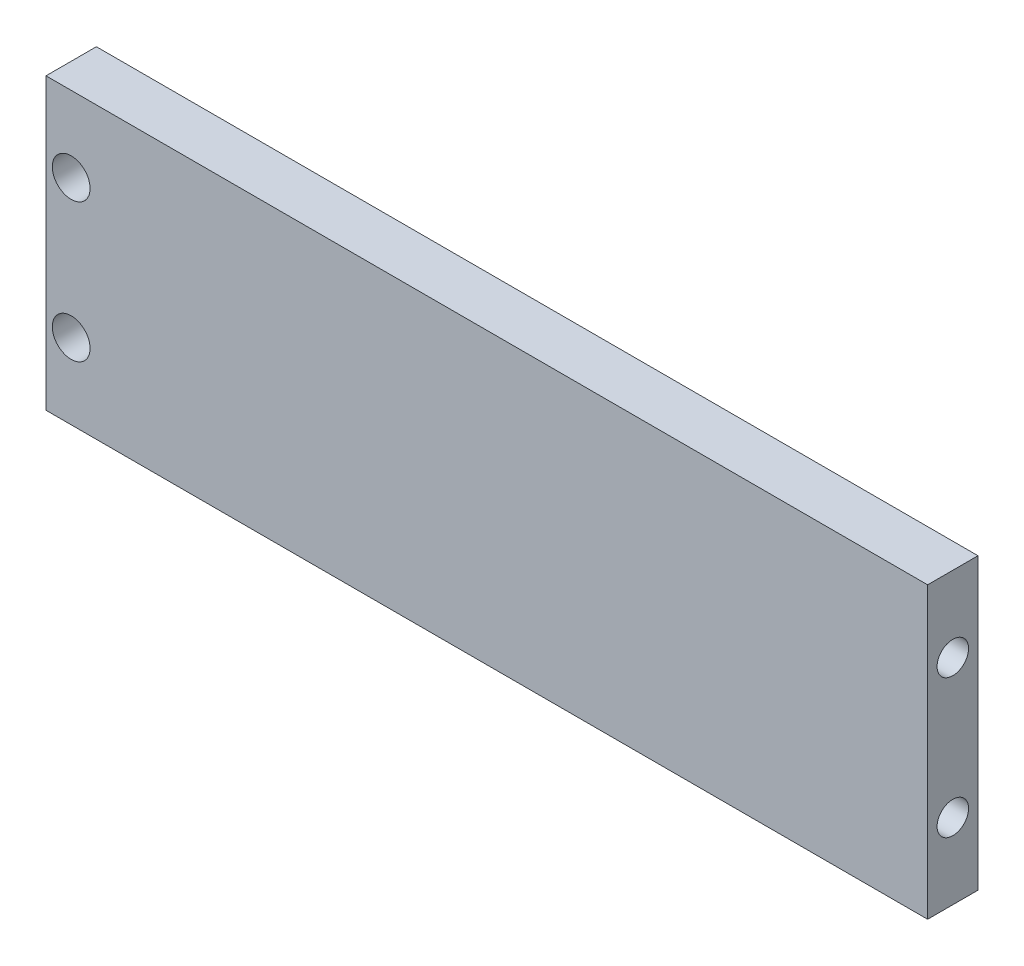
from build123d import *

# Parameters (mm, degrees)
ESBO_O1_W                = 70
ESBO_O1_H                = 23
RESSALTO_EXTRUS_O1_DEPTH = 4
ESBO_O2_R                = 1.25
CORTE_EXTRUS_O1_DEPTH    = 10
ESBO_O3_R                = 1.25
CORTE_EXTRUS_O2_DEPTH    = 10
ESBO_O4_R                = 1.5
CORTE_EXTRUS_O3_DEPTH    = 10


with BuildPart() as part:
    # Esboço1 → Ressalto-extrusão1 (new body)
    with BuildSketch(Plane.XY):
        with Locations((35, -11.5)):
            Rectangle(ESBO_O1_W, ESBO_O1_H)
    extrude(amount=RESSALTO_EXTRUS_O1_DEPTH)

    # Esboço2 → Corte-extrusão1 (cut)
    with BuildSketch(Plane(origin=(70, 0, 0), x_dir=(0, 0, -1), z_dir=(1, 0, 0))):
        with Locations((-2, -6)):
            Circle(ESBO_O2_R)
        with Locations((-2, -17)):
            Circle(ESBO_O2_R)
    extrude(amount=-CORTE_EXTRUS_O1_DEPTH, mode=Mode.SUBTRACT)

    # Esboço3 → Corte-extrusão2 (cut)
    with BuildSketch(Plane(origin=(0, -23, 0), x_dir=(-1, 0, 0), z_dir=(0, -1, 0))):
        with Locations((-15, -2)):
            Circle(ESBO_O3_R)
        with Locations((-35, -2)):
            Circle(ESBO_O3_R)
        with Locations((-55, -2)):
            Circle(ESBO_O3_R)
    extrude(amount=-CORTE_EXTRUS_O2_DEPTH, mode=Mode.SUBTRACT)

    # Esboço4 → Corte-extrusão3 (cut)
    with BuildSketch(Plane.XY.offset(4)):
        with Locations((2, -6)):
            Circle(ESBO_O4_R)
        with Locations((2, -17)):
            Circle(ESBO_O4_R)
    extrude(amount=-CORTE_EXTRUS_O3_DEPTH, mode=Mode.SUBTRACT)


solid = part.part
